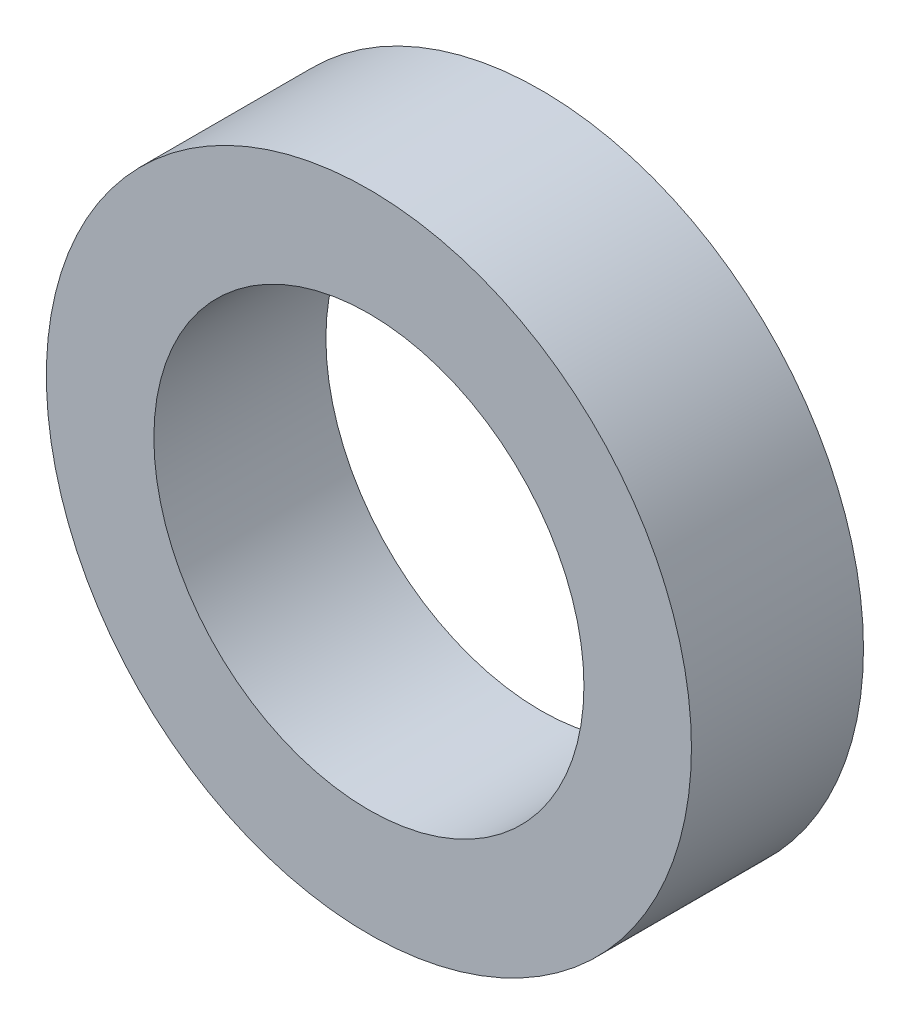
from build123d import *

# Parameters (mm, degrees)
SKETCH1_R           = 7.5
SKETCH1_R_2         = 5
BOSS_EXTRUDE1_DEPTH = 2


with BuildPart() as part:
    # Sketch1 → Boss-Extrude1 (new, symmetric)
    with BuildSketch(Plane.XY):
        Circle(SKETCH1_R)
        Circle(SKETCH1_R_2, mode=Mode.SUBTRACT)
    extrude(amount=BOSS_EXTRUDE1_DEPTH, both=True)


solid = part.part
